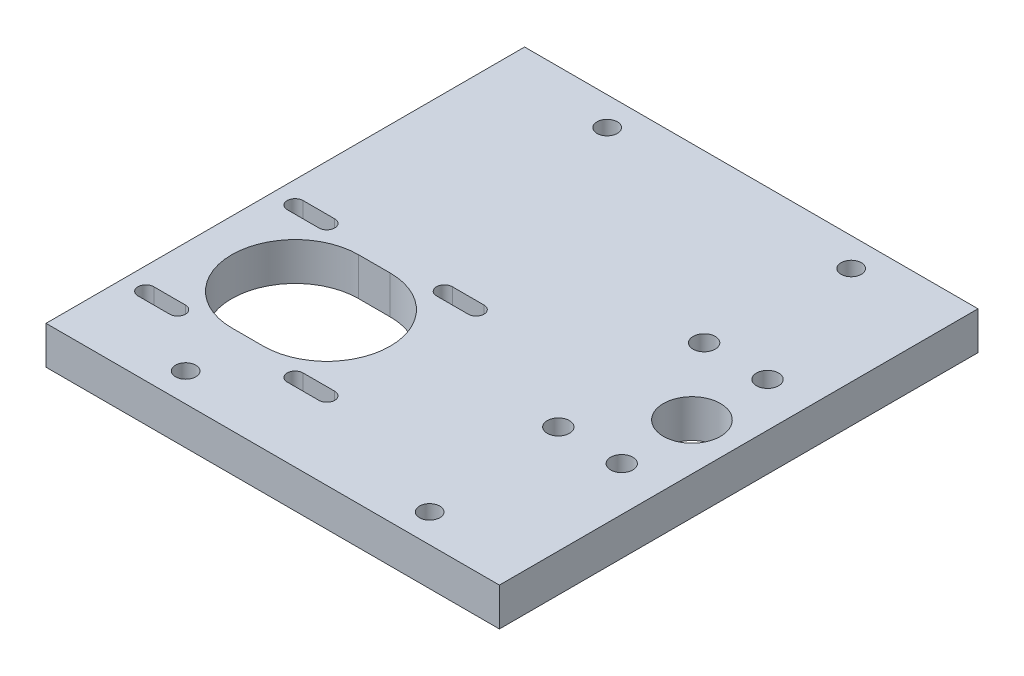
from build123d import *

# Parameters (mm, degrees)
SKETCH1_W           = 147
SKETCH1_H           = 151
BOSS_EXTRUDE1_DEPTH = 12
SKETCH2_R           = 9
SKETCH2_R_2         = 3.5
CUT_EXTRUDE1_DEPTH  = 13
SKETCH6_W           = 15
SKETCH6_H           = 151
BOSS_EXTRUDE2_DEPTH = 12
CUT_EXTRUDE3_DEPTH  = 13
SKETCH5_W           = 18.95
SKETCH5_H           = 151
CUT_EXTRUDE4_DEPTH  = 13
SKETCH7_R           = 3.2
CUT_EXTRUDE5_DEPTH  = 13


with BuildPart() as part:
    # Sketch1 → Boss-Extrude1 (new body)
    with BuildSketch(Plane(origin=(0, 0, 0), x_dir=(1, 0, 0), z_dir=(0, 1, 0))):
        Rectangle(SKETCH1_W, SKETCH1_H)
    extrude(amount=BOSS_EXTRUDE1_DEPTH)

    # Sketch2 → Cut-Extrude1 (cut, through all)
    with BuildSketch(Plane(origin=(0, 12, 0), x_dir=(1, 0, 0), z_dir=(0, 1, 0))):
        with Locations((39.8, 0)):
            Circle(SKETCH2_R)
        with Locations((20.65, -23)):
            Circle(SKETCH2_R_2)
        with Locations((40.65, -23)):
            Circle(SKETCH2_R_2)
        with Locations((40.65, 23)):
            Circle(SKETCH2_R_2)
        with Locations((20.65, 23)):
            Circle(SKETCH2_R_2)
    extrude(amount=-CUT_EXTRUDE1_DEPTH, mode=Mode.SUBTRACT)

    # Sketch6 → Boss-Extrude2 (add)
    with BuildSketch(Plane(origin=(0, 12, 0), x_dir=(1, 0, 0), z_dir=(0, 1, 0))):
        with Locations((-81, 0)):
            Rectangle(SKETCH6_W, SKETCH6_H)
    extrude(amount=-BOSS_EXTRUDE2_DEPTH)

    # Sketch4 → Cut-Extrude3 (cut, through all)
    with BuildSketch(Plane.XZ):
        with BuildLine():
            Line((-71.5, 53.5), (-81.5, 53.5))
            ThreePointArc((-81.5, 53.5), (-84, 51), (-81.5, 48.5))
            Line((-81.5, 48.5), (-71.5, 48.5))
            ThreePointArc((-71.5, 48.5), (-69, 51), (-71.5, 53.5))
        make_face()
        with BuildLine():
            Line((-71.5, 6.4), (-81.5, 6.4))
            ThreePointArc((-81.5, 6.4), (-84, 3.9), (-81.5, 1.4))
            Line((-81.5, 1.4), (-71.5, 1.4))
            ThreePointArc((-71.5, 1.4), (-69, 3.9), (-71.5, 6.4))
        make_face()
        with BuildLine():
            Line((-57.95, 47.45), (-47.95, 47.45))
            ThreePointArc((-47.95, 47.45), (-27.95, 27.45), (-47.95, 7.45))
            Line((-47.95, 7.45), (-57.95, 7.45))
            ThreePointArc((-57.95, 7.45), (-77.95, 27.45), (-57.95, 47.45))
        make_face()
        with BuildLine():
            Line((-34.4, 1.4), (-24.4, 1.4))
            ThreePointArc((-24.4, 1.4), (-21.9, 3.9), (-24.4, 6.4))
            Line((-24.4, 6.4), (-34.4, 6.4))
            ThreePointArc((-34.4, 6.4), (-36.9, 3.9), (-34.4, 1.4))
        make_face()
        with BuildLine():
            Line((-34.4, 48.5), (-24.4, 48.5))
            ThreePointArc((-24.4, 48.5), (-21.9, 51), (-24.4, 53.5))
            Line((-24.4, 53.5), (-34.4, 53.5))
            ThreePointArc((-34.4, 53.5), (-36.9, 51), (-34.4, 48.5))
        make_face()
    extrude(amount=-CUT_EXTRUDE3_DEPTH, mode=Mode.SUBTRACT)

    # Sketch5 → Cut-Extrude4 (cut, through all)
    with BuildSketch(Plane(origin=(0, 12, 0), x_dir=(1, 0, 0), z_dir=(0, 1, 0))):
        with Locations((64.025, 0)):
            Rectangle(SKETCH5_W, SKETCH5_H)
    extrude(amount=-CUT_EXTRUDE4_DEPTH, mode=Mode.SUBTRACT)

    # Sketch7 → Cut-Extrude5 (cut, through all)
    with BuildSketch(Plane(origin=(0, 12, 0), x_dir=(1, 0, 0), z_dir=(0, 1, 0))):
        with Locations((23.55, -66.5)):
            Circle(SKETCH7_R)
        with Locations((-53.45, -66.5)):
            Circle(SKETCH7_R)
        with Locations((-53.45, 66.5)):
            Circle(SKETCH7_R)
        with Locations((23.55, 66.5)):
            Circle(SKETCH7_R)
    extrude(amount=-CUT_EXTRUDE5_DEPTH, mode=Mode.SUBTRACT)


solid = part.part
